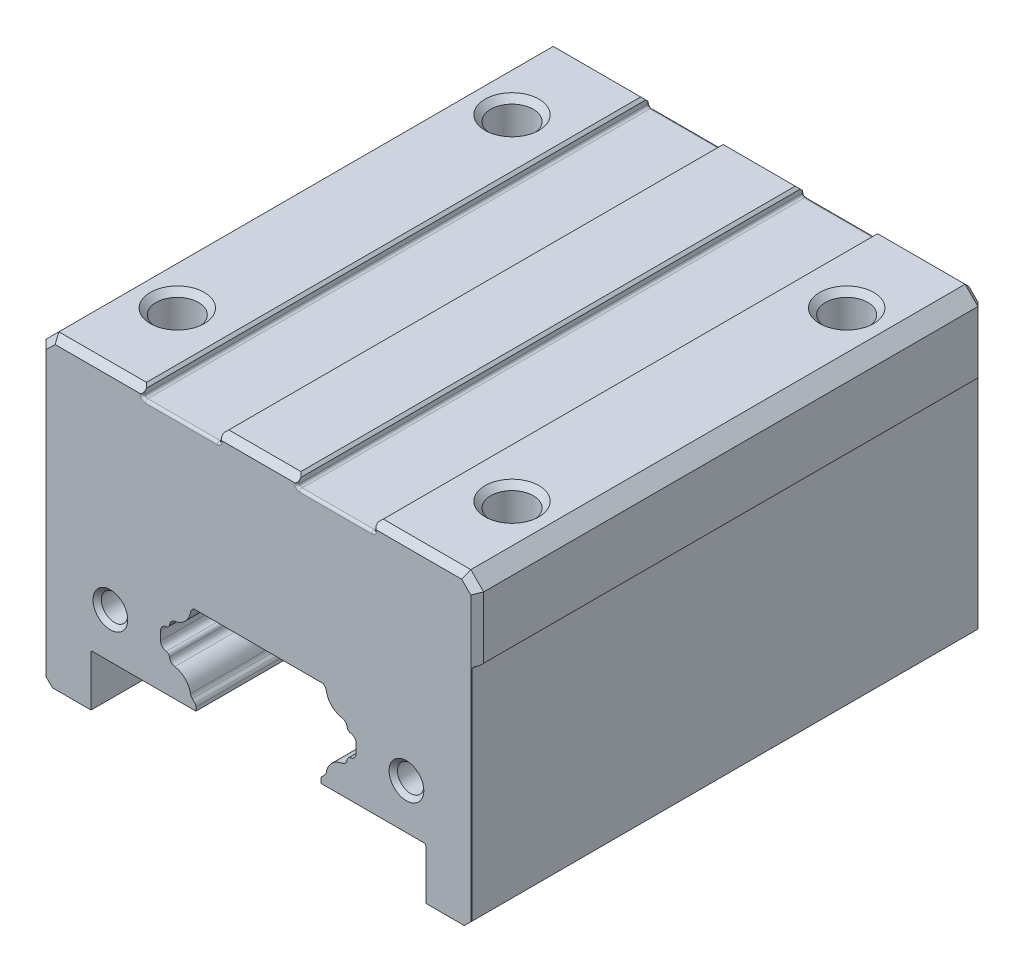
from build123d import *

# Parameters (mm, degrees)
BLOCK_BODY_DEPTH                       = 19.7
SIDE_REFERENCE_SKETCH_W                = 40
SIDE_REFERENCE_SKETCH_H                = 20
SIDE_REFERENCE_DEPTH                   = 0.45
AESTHETIC_CHAMFER_1_SIZE               = 0.5
CASTING_GROOVE_SKETCH_W                = 6
CASTING_GROOVE_SKETCH_H                = 40
CASTING_GOORVE_DEPTH                   = 0.75
AESTHETIC_CHAMFER_2_SIZE               = 0.2
PRODUCTION_FILLET_R                    = 0.2
FIXING_HOLES_D                         = 3.3
FIXING_HOLES_DEPTH                     = 7.1
FIXING_HOLES_CSINK_D                   = 4.2
FIXING_HOLES_CSINK_ANGLE               = 90
FIXING_HOLES_TIP                       = 0.991420021
END_CAP_FIXING_HOLES_FRONT_D           = 2.05
END_CAP_FIXING_HOLES_FRONT_DEPTH       = 6.35
END_CAP_FIXING_HOLES_FRONT_CSINK_D     = 2.7
END_CAP_FIXING_HOLES_FRONT_CSINK_ANGLE = 90
END_CAP_FIXING_HOLES_FRONT_TIP         = 0.615882135
END_CAP_FIXING_HOLES_BACK_D            = 2.05
END_CAP_FIXING_HOLES_BACK_DEPTH        = 6.35
END_CAP_FIXING_HOLES_BACK_CSINK_D      = 2.7
END_CAP_FIXING_HOLES_BACK_CSINK_ANGLE  = 90
END_CAP_FIXING_HOLES_BACK_TIP          = 0.615882135


with BuildPart() as part:
    # Block Profile → Block Body (new body, symmetric)
    with BuildSketch(Plane.XY):
        with BuildLine():
            Line((16, 4.3), (13, 4.3))
            Line((13, 4.3), (13, 8.2))
            ThreePointArc((13, 8.2), (12.970710678, 8.270710678), (12.9, 8.3))
            Line((12.9, 8.3), (4.85, 8.3))
            Line((4.85, 8.3), (4.85, 8.584314575))
            ThreePointArc((4.85, 8.584314575), (4.87283614, 8.699119605), (4.937867966, 8.796446609))
            Line((4.937867966, 8.796446609), (5.13367604, 8.992254684))
            ThreePointArc((5.13367604, 8.992254684), (5.223715255, 9.115101334), (5.272591987, 9.259356056))
            ThreePointArc((5.272591987, 9.259356056), (5.689339828, 10.060660172), (6.490643944, 10.477408013))
            ThreePointArc((6.490643944, 10.477408013), (6.766607459, 10.625414027), (6.900414725, 10.908534598))
            ThreePointArc((6.900414725, 10.908534598), (6.98601637, 11.08386098), (7.161342753, 11.169462626))
            ThreePointArc((7.161342753, 11.169462626), (7.474614052, 11.334529402), (7.6, 11.665685425))
            Line((7.6, 11.665685425), (7.6, 12.334314575))
            ThreePointArc((7.6, 12.334314575), (7.474614052, 12.665470598), (7.161342753, 12.830537374))
            ThreePointArc((7.161342753, 12.830537374), (6.98601637, 12.91613902), (6.900414725, 13.091465402))
            ThreePointArc((6.900414725, 13.091465402), (6.766607459, 13.374585973), (6.490643944, 13.522591987))
            ThreePointArc((6.490643944, 13.522591987), (5.689339828, 13.939339828), (5.272591987, 14.740643944))
            ThreePointArc((5.272591987, 14.740643944), (5.223715255, 14.884898666), (5.13367604, 15.007745316))
            Line((5.13367604, 15.007745316), (5.041421356, 15.1))
            Line((5.041421356, 15.1), (-5.041421356, 15.1))
            Line((-5.041421356, 15.1), (-5.13367604, 15.007745316))
            ThreePointArc((-5.13367604, 15.007745316), (-5.223715255, 14.884898666), (-5.272591987, 14.740643944))
            ThreePointArc((-5.272591987, 14.740643944), (-5.689339828, 13.939339828), (-6.490643944, 13.522591987))
            ThreePointArc((-6.490643944, 13.522591987), (-6.766607459, 13.374585973), (-6.900414725, 13.091465402))
            ThreePointArc((-6.900414725, 13.091465402), (-6.98601637, 12.91613902), (-7.161342753, 12.830537374))
            ThreePointArc((-7.161342753, 12.830537374), (-7.474614052, 12.665470598), (-7.6, 12.334314575))
            Line((-7.6, 12.334314575), (-7.6, 11.665685425))
            ThreePointArc((-7.6, 11.665685425), (-7.474614052, 11.334529402), (-7.161342753, 11.169462626))
            ThreePointArc((-7.161342753, 11.169462626), (-6.98601637, 11.08386098), (-6.900414725, 10.908534598))
            ThreePointArc((-6.900414725, 10.908534598), (-6.766607459, 10.625414027), (-6.490643944, 10.477408013))
            ThreePointArc((-6.490643944, 10.477408013), (-5.689339828, 10.060660172), (-5.272591987, 9.259356056))
            ThreePointArc((-5.272591987, 9.259356056), (-5.223715255, 9.115101334), (-5.13367604, 8.992254684))
            Line((-5.13367604, 8.992254684), (-4.937867966, 8.796446609))
            ThreePointArc((-4.937867966, 8.796446609), (-4.87283614, 8.699119605), (-4.85, 8.584314575))
            Line((-4.85, 8.584314575), (-4.85, 8.3))
            Line((-4.85, 8.3), (-12.9, 8.3))
            ThreePointArc((-12.9, 8.3), (-12.970710678, 8.270710678), (-13, 8.2))
            Line((-13, 8.2), (-13, 4.3))
            Line((-13, 4.3), (-16, 4.3))
            Line((-16, 4.3), (-17, 5.3))
            Line((-17, 5.3), (-17, 27))
            Line((-17, 27), (-16, 28))
            Line((-16, 28), (16, 28))
            Line((16, 28), (17, 27))
            Line((17, 27), (17, 5.3))
            Line((17, 5.3), (16, 4.3))
        make_face()
    extrude(amount=BLOCK_BODY_DEPTH, both=True)

    # Side Reference Sketch → Side Reference (cut)
    with BuildSketch(Plane(origin=(17, 0, 0), x_dir=(0, 0, -1), z_dir=(1, 0, 0))):
        with Locations((0, 12)):
            Rectangle(SIDE_REFERENCE_SKETCH_W, SIDE_REFERENCE_SKETCH_H)
    extrude(amount=-SIDE_REFERENCE_DEPTH, mode=Mode.SUBTRACT)

    # Aesthetic Chamfer 1
    aesthetic_chamfer_1_edges = [part.edges().sort_by_distance(p)[0] for p in [
        (-17, 16.15, -19.7),
        (-16.5, 27.5, -19.7),
        (0, 28, -19.7),
        (16.5, 27.5, -19.7),
        (17, 24.5, -19.7),
        (-17, 16.15, 19.7),
        (-16.5, 27.5, 19.7),
        (17, 24.5, 19.7),
        (16.5, 27.5, 19.7),
        (0, 28, 19.7),
    ]]
    chamfer(aesthetic_chamfer_1_edges, length=AESTHETIC_CHAMFER_1_SIZE)

    # Casting Groove Sketch → Casting Goorve (cut)
    with BuildSketch(Plane(origin=(0, 28, 0), x_dir=(1, 0, 0), z_dir=(0, 1, 0))):
        with Locations((-6, 0)):
            Rectangle(CASTING_GROOVE_SKETCH_W, CASTING_GROOVE_SKETCH_H)
        with Locations((6, 0)):
            Rectangle(CASTING_GROOVE_SKETCH_W, CASTING_GROOVE_SKETCH_H)
    extrude(amount=-CASTING_GOORVE_DEPTH, mode=Mode.SUBTRACT)

    # Aesthetic Chamfer 2
    aesthetic_chamfer_2_edges = [part.edges().sort_by_distance(p)[0] for p in [
        (17, 22, 0),
        (-9, 28, 0),
        (-3, 28, 0),
        (3, 28, 0),
        (9, 28, 0),
    ]]
    chamfer(aesthetic_chamfer_2_edges, length=AESTHETIC_CHAMFER_2_SIZE)

    # Production Fillet
    production_fillet_edges = [part.edges().sort_by_distance(p)[0] for p in [
        (16.55, 22, 0),
        (6, 27.25, -19.7),
        (-6, 27.25, -19.7),
        (-3, 27.375, -19.7),
        (-3, 27.375, 19.7),
        (-3, 27.25, 0),
        (-9, 27.375, -19.7),
        (-9, 27.25, 0),
        (-9, 27.375, 19.7),
        (-6, 27.25, 19.7),
        (9, 27.375, -19.7),
        (9, 27.375, 19.7),
        (9, 27.25, 0),
        (3, 27.375, -19.7),
        (3, 27.25, 0),
        (3, 27.375, 19.7),
        (6, 27.25, 19.7),
    ]]
    fillet(production_fillet_edges, radius=PRODUCTION_FILLET_R)

    # Fixing Holes
    with Locations(Plane(origin=(0, 28, 0), x_dir=(1, 0, 0), z_dir=(0, 1, 0))):
        with Locations((-13, -13), (-13, 13), (13, 13), (13, -13)):
            CounterSinkHole(FIXING_HOLES_D / 2, FIXING_HOLES_CSINK_D / 2, depth=FIXING_HOLES_DEPTH, counter_sink_angle=FIXING_HOLES_CSINK_ANGLE)
            with Locations((0, 0, -(FIXING_HOLES_DEPTH + FIXING_HOLES_TIP / 2))):  # 118° drill point
                Cone(0, FIXING_HOLES_D / 2, FIXING_HOLES_TIP, mode=Mode.SUBTRACT)

    # End Cap Fixing Holes Front
    with Locations(Plane.XY.offset(19.7)):
        with Locations((-11.5, 11.8), (11.5, 11.8)):
            CounterSinkHole(END_CAP_FIXING_HOLES_FRONT_D / 2, END_CAP_FIXING_HOLES_FRONT_CSINK_D / 2, depth=END_CAP_FIXING_HOLES_FRONT_DEPTH, counter_sink_angle=END_CAP_FIXING_HOLES_FRONT_CSINK_ANGLE)
            with Locations((0, 0, -(END_CAP_FIXING_HOLES_FRONT_DEPTH + END_CAP_FIXING_HOLES_FRONT_TIP / 2))):  # 118° drill point
                Cone(0, END_CAP_FIXING_HOLES_FRONT_D / 2, END_CAP_FIXING_HOLES_FRONT_TIP, mode=Mode.SUBTRACT)

    # End Cap Fixing Holes Back
    with Locations(Plane(origin=(0, 0, -19.7), x_dir=(-1, 0, 0), z_dir=(0, 0, -1))):
        with Locations((-11.5, 11.8), (11.5, 11.8)):
            CounterSinkHole(END_CAP_FIXING_HOLES_BACK_D / 2, END_CAP_FIXING_HOLES_BACK_CSINK_D / 2, depth=END_CAP_FIXING_HOLES_BACK_DEPTH, counter_sink_angle=END_CAP_FIXING_HOLES_BACK_CSINK_ANGLE)
            with Locations((0, 0, -(END_CAP_FIXING_HOLES_BACK_DEPTH + END_CAP_FIXING_HOLES_BACK_TIP / 2))):  # 118° drill point
                Cone(0, END_CAP_FIXING_HOLES_BACK_D / 2, END_CAP_FIXING_HOLES_BACK_TIP, mode=Mode.SUBTRACT)


solid = part.part
